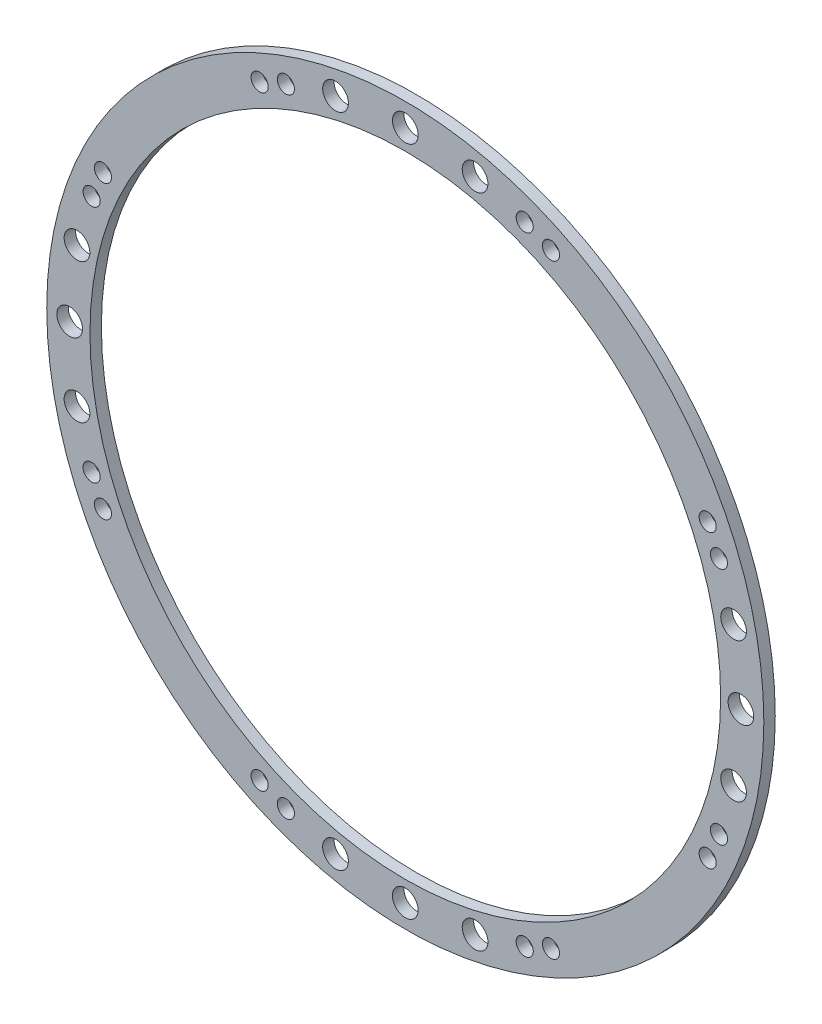
from build123d import *

# Parameters (mm, degrees)
SKETCH1_R           = 50.2
SKETCH1_R_2         = 44.15
BOSS_EXTRUDE1_DEPTH = 1.6
SKETCH2_R           = 1.8
SKETCH2_R_2         = 1.2
CUT_EXTRUDE1_DEPTH  = 2.6
CIRPATTERN1_COUNT   = 4


with BuildPart() as part:
    # Sketch1 → Boss-Extrude1 (new body)
    with BuildSketch(Plane.XY):
        Circle(SKETCH1_R)
        Circle(SKETCH1_R_2, mode=Mode.SUBTRACT)
    extrude(amount=BOSS_EXTRUDE1_DEPTH)

    # Sketch2 → Cut-Extrude1 (cut, through all)
    with BuildSketch(Plane.XY.offset(1.6)):
        with Locations((-45.963155758, 9.769770352)):
            Circle(SKETCH2_R)
        with Locations((-9.769770352, 45.963155758)):
            Circle(SKETCH2_R)
        with Locations((-42.333815877, 20.393825862)):
            Circle(SKETCH2_R_2)
        with Locations((-43.914877634, 16.719558081)):
            Circle(SKETCH2_R_2)
        with Locations((-20.393825862, 42.333815877)):
            Circle(SKETCH2_R_2)
        with Locations((-16.719558081, 43.914877634)):
            Circle(SKETCH2_R_2)
        with Locations((-46.99, 0)):
            Circle(SKETCH2_R)
        with Locations((0, 46.99)):
            Circle(SKETCH2_R)
    cut_extrude1 = extrude(amount=-CUT_EXTRUDE1_DEPTH, mode=Mode.SUBTRACT)

    # CirPattern1: Cut-Extrude1 ×4 about axis
    cirpattern1_axis = Axis((0, 0, 0), (0, 0, 1))
    for i in range(1, CIRPATTERN1_COUNT):
        add(cut_extrude1.rotate(cirpattern1_axis, i * 360 / CIRPATTERN1_COUNT), mode=Mode.SUBTRACT)


solid = part.part
